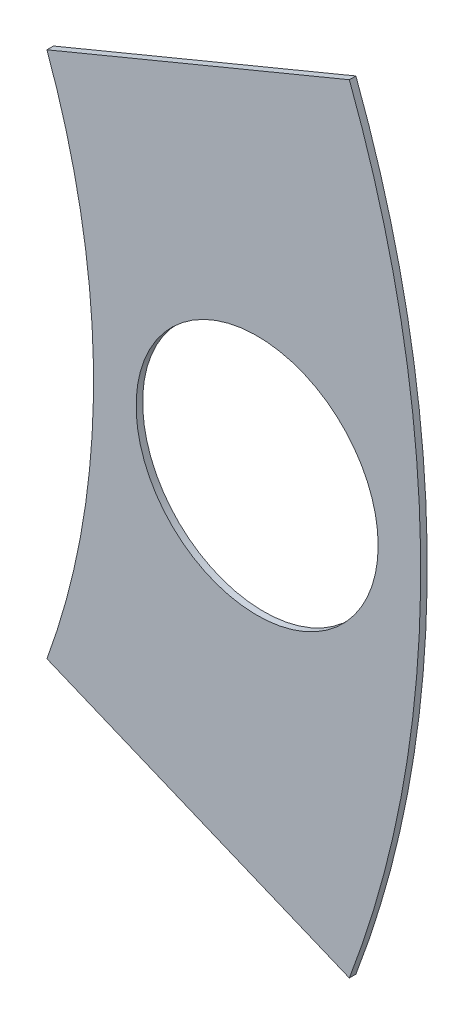
from build123d import *

# Parameters (mm, degrees)
SKETCH4_R           = 42.545
BOSS_EXTRUDE2_DEPTH = 0.254
SKETCH5_R           = 29.845
CUT_EXTRUDE5_DEPTH  = 1.254
SKETCH6_R           = 4.699
CUT_EXTRUDE6_DEPTH  = 1.254
SKETCH8_OUTSIDE_W   = 111.158
SKETCH8_OUTSIDE_H   = 111.158
CUT_EXTRUDE11_DEPTH = 1.254


with BuildPart() as part:
    # Sketch4 → Boss-Extrude2 (new body)
    with BuildSketch(Plane.XY):
        Circle(SKETCH4_R)
    extrude(amount=BOSS_EXTRUDE2_DEPTH)

    # Sketch5 → Cut-Extrude5 (cut, through all)
    with BuildSketch(Plane.XY.offset(0.254)):
        Circle(SKETCH5_R)
    extrude(amount=-CUT_EXTRUDE5_DEPTH, mode=Mode.SUBTRACT)

    # Sketch6 → Cut-Extrude6 (cut, through all)
    with BuildSketch(Plane.XY.offset(0.254)):
        with Locations((36.195, 0)):
            Circle(SKETCH6_R)
    extrude(amount=-CUT_EXTRUDE6_DEPTH, mode=Mode.SUBTRACT)

    # Sketch8 outside → Cut-Extrude11 (cut, through all)
    with BuildSketch(Plane.XY.offset(0.254)):
        Rectangle(SKETCH8_OUTSIDE_W, SKETCH8_OUTSIDE_H)
        with BuildLine():
            Line((28.034216891, -10.237514752), (39.774946424, -15.100684157))
            ThreePointArc((39.774946424, -15.100684157), (42.545, 0), (39.774946424, 15.100684157))
            Line((39.774946424, 15.100684157), (28.034216891, 10.237514752))
            ThreePointArc((28.034216891, 10.237514752), (29.845, 0), (28.034216891, -10.237514752))
        make_face(mode=Mode.SUBTRACT)
    extrude(amount=-CUT_EXTRUDE11_DEPTH, mode=Mode.SUBTRACT)


solid = part.part
